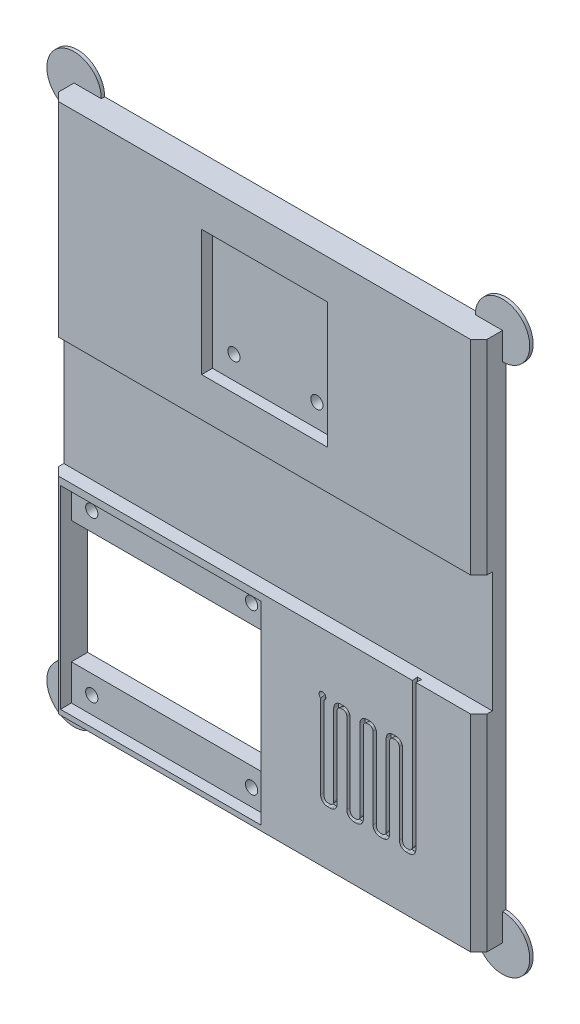
from build123d import *

# Parameters (mm, degrees)
SKETCH5_W           = 63
SKETCH5_H           = 78
BOSS_EXTRUDE2_DEPTH = 4
TEENSY_W            = 63
TEENSY_H            = 17.7
CUT_EXTRUDE3_DEPTH  = 2
SKETCH7_W           = 18.5
SKETCH7_H           = 18.5
CUT_EXTRUDE4_DEPTH  = 1.6
SKETCH8_W           = 29.5
SKETCH8_H           = 28.5
CUT_EXTRUDE5_DEPTH  = 1.6
SKETCH9_R           = 0.9
SKETCH9_W           = 29
SKETCH9_H           = 18
CUT_EXTRUDE6_DEPTH  = 3.4
SKETCH10_R          = 4
BOSS_EXTRUDE3_DEPTH = 0.5
CHAMFER2_SIZE       = 1.2
CUT_EXTRUDE8_DEPTH  = 0.8
CUT_EXTRUDE8_TAPER  = -5
SKETCH13_R          = 0.5
CUT_EXTRUDE9_DEPTH  = 5


with BuildPart() as part:
    # Sketch5 → Boss-Extrude2 (new body)
    with BuildSketch(Plane.XY):
        with Locations((0, 9)):
            Rectangle(SKETCH5_W, SKETCH5_H)
    extrude(amount=BOSS_EXTRUDE2_DEPTH)

    # Teensy → Cut-Extrude3 (cut)
    with BuildSketch(Plane.XY.offset(4)):
        with Locations((0, 9.15)):
            Rectangle(TEENSY_W, TEENSY_H)
    extrude(amount=-CUT_EXTRUDE3_DEPTH, mode=Mode.SUBTRACT)

    # Sketch7 → Cut-Extrude4 (cut)
    with BuildSketch(Plane.XY.offset(4)):
        with Locations((0, 33)):
            Rectangle(SKETCH7_W, SKETCH7_H)
    extrude(amount=-CUT_EXTRUDE4_DEPTH, mode=Mode.SUBTRACT)

    # Sketch8 → Cut-Extrude5 (cut)
    with BuildSketch(Plane.XY.offset(4)):
        with Locations((-15.25, -15)):
            Rectangle(SKETCH8_W, SKETCH8_H)
    extrude(amount=-CUT_EXTRUDE5_DEPTH, mode=Mode.SUBTRACT)

    # Sketch9 → Cut-Extrude6 (cut, through all)
    with BuildSketch(Plane.XY.offset(2.4)):
        with Locations((-27, -3.25)):
            Circle(SKETCH9_R)
        with Locations((-3.5, -3.25)):
            Circle(SKETCH9_R)
        with Locations((-3.5, -26.75)):
            Circle(SKETCH9_R)
        with Locations((-27, -26.75)):
            Circle(SKETCH9_R)
        with Locations((-6.1, 27.113992779)):
            Circle(SKETCH9_R)
        with Locations((6.1, 27.113992779)):
            Circle(SKETCH9_R)
        with Locations((-15.5, -15)):
            Rectangle(SKETCH9_W, SKETCH9_H)
    extrude(amount=-CUT_EXTRUDE6_DEPTH, mode=Mode.SUBTRACT)

    # Sketch10 → Boss-Extrude3 (add)
    with BuildSketch(Plane(origin=(0, 0, 0), x_dir=(-1, 0, 0), z_dir=(0, 0, -1))):
        with Locations((31.5, 48)):
            Circle(SKETCH10_R)
        with Locations((-31.5, 48)):
            Circle(SKETCH10_R)
        with Locations((-31.5, -30)):
            Circle(SKETCH10_R)
        with Locations((31.5, -30)):
            Circle(SKETCH10_R)
    extrude(amount=-BOSS_EXTRUDE3_DEPTH)

    # Chamfer2
    chamfer2_edges = [part.edges().sort_by_distance(p)[0] for p in [
        (31.5, -14.85, 4),
        (-31.5, -14.85, 4),
        (31.5, 33, 4),
        (-31.5, 33, 4),
    ]]
    chamfer(chamfer2_edges, length=CHAMFER2_SIZE)

    # Sketch12 → Cut-Extrude8 (cut)
    with BuildSketch(Plane.XY.offset(4)):
        with BuildLine():
            Line((21.75, 0.3), (21.75, -20.9))
            ThreePointArc((21.75, -20.9), (21.574264069, -21.324264069), (21.15, -21.5))
            Line((21.15, -21.5), (20.921428571, -21.5))
            ThreePointArc((20.921428571, -21.5), (20.497164503, -21.324264069), (20.321428571, -20.9))
            Line((20.321428571, -20.9), (20.321428571, -9))
            ThreePointArc((20.321428571, -9), (20.028535353, -8.292893219), (19.321428571, -8))
            Line((19.321428571, -8), (18.892857143, -8))
            ThreePointArc((18.892857143, -8), (18.185750362, -8.292893219), (17.892857143, -9))
            Line((17.892857143, -9), (17.892857143, -20.9))
            ThreePointArc((17.892857143, -20.9), (17.717121212, -21.324264069), (17.292857143, -21.5))
            Line((17.292857143, -21.5), (17.064285714, -21.5))
            ThreePointArc((17.064285714, -21.5), (16.640021646, -21.324264069), (16.464285714, -20.9))
            Line((16.464285714, -20.9), (16.464285714, -9))
            ThreePointArc((16.464285714, -9), (16.171392495, -8.292893219), (15.464285714, -8))
            Line((15.464285714, -8), (15.035714286, -8))
            ThreePointArc((15.035714286, -8), (14.328607505, -8.292893219), (14.035714286, -9))
            Line((14.035714286, -9), (14.035714286, -20.9))
            ThreePointArc((14.035714286, -20.9), (13.859978354, -21.324264069), (13.435714286, -21.5))
            Line((13.435714286, -21.5), (13.207142857, -21.5))
            ThreePointArc((13.207142857, -21.5), (12.782878788, -21.324264069), (12.607142857, -20.9))
            Line((12.607142857, -20.9), (12.607142857, -9))
            ThreePointArc((12.607142857, -9), (12.314249638, -8.292893219), (11.607142857, -8))
            Line((11.607142857, -8), (11.178571429, -8))
            ThreePointArc((11.178571429, -8), (10.471464647, -8.292893219), (10.178571429, -9))
            Line((10.178571429, -9), (10.178571429, -20.9))
            ThreePointArc((10.178571429, -20.9), (10.002835497, -21.324264069), (9.578571429, -21.5))
            Line((9.578571429, -21.5), (9.35, -21.5))
            ThreePointArc((9.35, -21.5), (8.925735931, -21.324264069), (8.75, -20.9))
            Line((8.75, -20.9), (8.75, -8.25))
            Line((8.75, -8.25), (8.25, -8.25))
            Line((8.25, -8.25), (8.25, -21))
            ThreePointArc((8.25, -21), (8.542893219, -21.707106781), (9.25, -22))
            Line((9.25, -22), (9.678571429, -22))
            ThreePointArc((9.678571429, -22), (10.38567821, -21.707106781), (10.678571429, -21))
            Line((10.678571429, -21), (10.678571429, -9.1))
            ThreePointArc((10.678571429, -9.1), (10.85430736, -8.675735931), (11.278571429, -8.5))
            Line((11.278571429, -8.5), (11.507142857, -8.5))
            ThreePointArc((11.507142857, -8.5), (11.931406926, -8.675735931), (12.107142857, -9.1))
            Line((12.107142857, -9.1), (12.107142857, -21))
            ThreePointArc((12.107142857, -21), (12.400036076, -21.707106781), (13.107142857, -22))
            Line((13.107142857, -22), (13.535714286, -22))
            ThreePointArc((13.535714286, -22), (14.242821067, -21.707106781), (14.535714286, -21))
            Line((14.535714286, -21), (14.535714286, -9.1))
            ThreePointArc((14.535714286, -9.1), (14.711450217, -8.675735931), (15.135714286, -8.5))
            Line((15.135714286, -8.5), (15.364285714, -8.5))
            ThreePointArc((15.364285714, -8.5), (15.788549783, -8.675735931), (15.964285714, -9.1))
            Line((15.964285714, -9.1), (15.964285714, -21))
            ThreePointArc((15.964285714, -21), (16.257178933, -21.707106781), (16.964285714, -22))
            Line((16.964285714, -22), (17.392857143, -22))
            ThreePointArc((17.392857143, -22), (18.099963924, -21.707106781), (18.392857143, -21))
            Line((18.392857143, -21), (18.392857143, -9.1))
            ThreePointArc((18.392857143, -9.1), (18.568593074, -8.675735931), (18.992857143, -8.5))
            Line((18.992857143, -8.5), (19.221428571, -8.5))
            ThreePointArc((19.221428571, -8.5), (19.64569264, -8.675735931), (19.821428571, -9.1))
            Line((19.821428571, -9.1), (19.821428571, -21))
            ThreePointArc((19.821428571, -21), (20.11432179, -21.707106781), (20.821428571, -22))
            Line((20.821428571, -22), (21.25, -22))
            ThreePointArc((21.25, -22), (21.957106781, -21.707106781), (22.25, -21))
            Line((22.25, -21), (22.25, 0.3))
            Line((22.25, 0.3), (21.75, 0.3))
        make_face()
    extrude(amount=-CUT_EXTRUDE8_DEPTH, taper=CUT_EXTRUDE8_TAPER, mode=Mode.SUBTRACT)

    # Sketch13 → Cut-Extrude9 (cut, through all)
    with BuildSketch(Plane.XY.offset(4)):
        with Locations((8.517174501, -8.25)):
            Circle(SKETCH13_R)
    extrude(amount=-CUT_EXTRUDE9_DEPTH, mode=Mode.SUBTRACT)


solid = part.part
